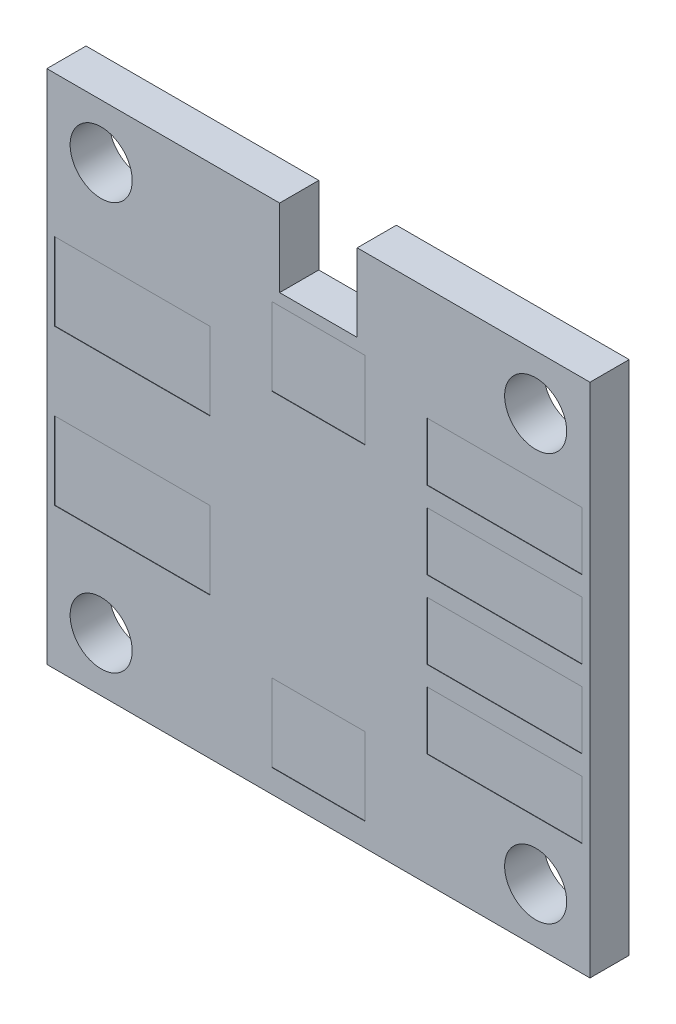
from build123d import *

# Parameters (mm, degrees)
SKETCH_1_R      = 0.8
EXTRUDE_2_DEPTH = 1
SKETCH_2_R      = 0.8
SKETCH_2_W      = 4
SKETCH_2_H      = 2
SKETCH_2_W_2    = 2.4
SKETCH_2_H_2    = 1.5
EXTRUDE_3_DEPTH = 0.01


with BuildPart() as part:
    # 草图1 → 凸台-拉伸2 (new body)
    with BuildSketch(Plane.XY):
        Polygon((0, 13.3), (0, 0), (14, 0), (14, 13.3), (8, 13.3), (8, 11.3), (6, 11.3), (6, 13.3), align=None)
        with Locations((1.4, 1.4)):
            Circle(SKETCH_1_R, mode=Mode.SUBTRACT)
        with Locations((12.6, 1.4)):
            Circle(SKETCH_1_R, mode=Mode.SUBTRACT)
        with Locations((1.4, 11.9)):
            Circle(SKETCH_1_R, mode=Mode.SUBTRACT)
        with Locations((12.6, 11.9)):
            Circle(SKETCH_1_R, mode=Mode.SUBTRACT)
    extrude(amount=EXTRUDE_2_DEPTH)

    # 草图2 → 凸台-拉伸3 (add)
    with BuildSketch(Plane.XY.offset(1)):
        Polygon((0, 0), (14, 0), (14, 13.3), (8, 13.3), (8, 11.3), (6, 11.3), (6, 13.3), (0, 13.3), align=None)
        with Locations((1.4, 1.4)):
            Circle(SKETCH_2_R, mode=Mode.SUBTRACT)
        with Locations((2.2, 4.65)):
            Rectangle(SKETCH_2_W, SKETCH_2_H, mode=Mode.SUBTRACT)
        with Locations((7, 1.6)):
            Rectangle(SKETCH_2_W_2, SKETCH_2_H, mode=Mode.SUBTRACT)
        with Locations((12.6, 1.4)):
            Circle(SKETCH_2_R, mode=Mode.SUBTRACT)
        with Locations((11.8, 3.65)):
            Rectangle(SKETCH_2_W, SKETCH_2_H_2, mode=Mode.SUBTRACT)
        with Locations((11.8, 5.65)):
            Rectangle(SKETCH_2_W, SKETCH_2_H_2, mode=Mode.SUBTRACT)
        with Locations((2.2, 8.65)):
            Rectangle(SKETCH_2_W, SKETCH_2_H, mode=Mode.SUBTRACT)
        with Locations((1.4, 11.9)):
            Circle(SKETCH_2_R, mode=Mode.SUBTRACT)
        with Locations((11.8, 7.65)):
            Rectangle(SKETCH_2_W, SKETCH_2_H_2, mode=Mode.SUBTRACT)
        with Locations((11.8, 9.65)):
            Rectangle(SKETCH_2_W, SKETCH_2_H_2, mode=Mode.SUBTRACT)
        with Locations((7, 10)):
            Rectangle(SKETCH_2_W_2, SKETCH_2_H, mode=Mode.SUBTRACT)
        with Locations((12.6, 11.9)):
            Circle(SKETCH_2_R, mode=Mode.SUBTRACT)
    extrude(amount=EXTRUDE_3_DEPTH)


solid = part.part
